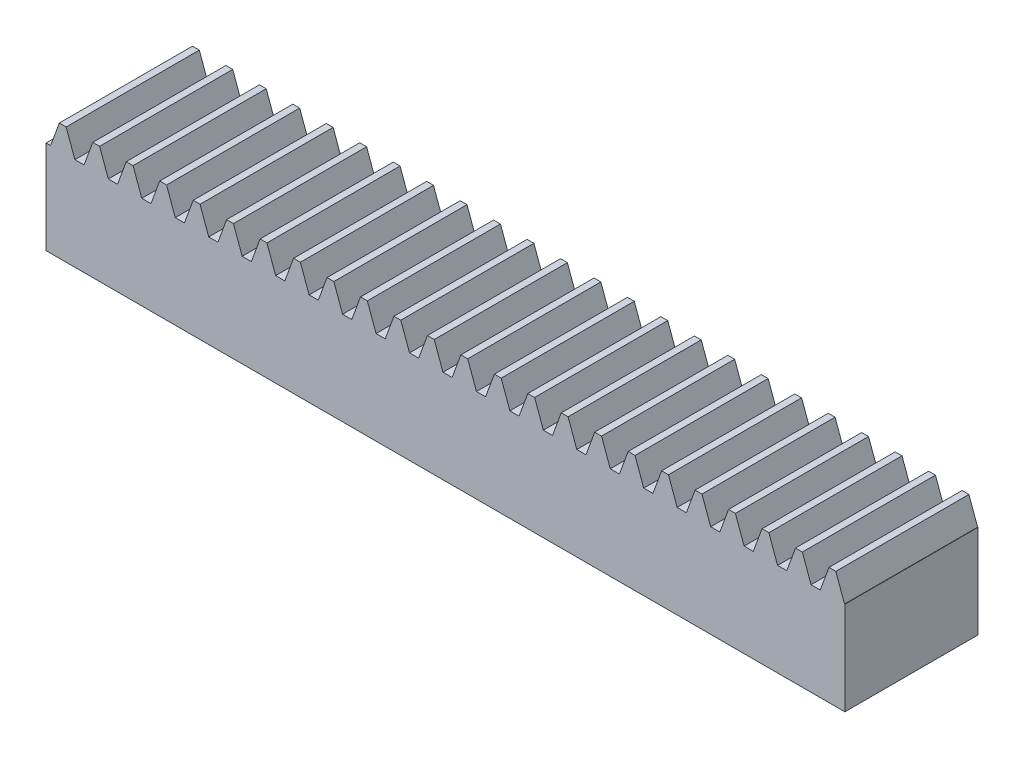
from build123d import *

# Parameters (mm, degrees)
BLANKSKE_W        = 150
BLANKSKE_H        = 22
BLANK_DEPTH       = 25
TOOTHCUTSIM_DEPTH = 154.65220467
TEETHCUTS_COUNT   = 25
TEETHCUTS_PITCH   = 6.2831853


with BuildPart() as part:
    # BlankSke → Blank (new body)
    with BuildSketch(Plane.XY):
        with Locations((75, 11)):
            Rectangle(BLANKSKE_W, BLANKSKE_H)
    extrude(amount=-BLANK_DEPTH)

    # TooCutSkeSim → ToothCutSim (cut, through all)
    with BuildSketch(Plane.XY):
        Polygon((0.861870739, 17.5), (-0.861870739, 17.5), (-2.508981637, 22.0254), (2.508981637, 22.0254), align=None)
    toothcutsim = extrude(amount=-TOOTHCUTSIM_DEPTH, mode=Mode.SUBTRACT)

    # TeethCuts: ToothCutSim ×25
    with Locations(*[(i * TEETHCUTS_PITCH, 0, 0) for i in range(1, TEETHCUTS_COUNT)]):
        add(toothcutsim, mode=Mode.SUBTRACT)


solid = part.part
